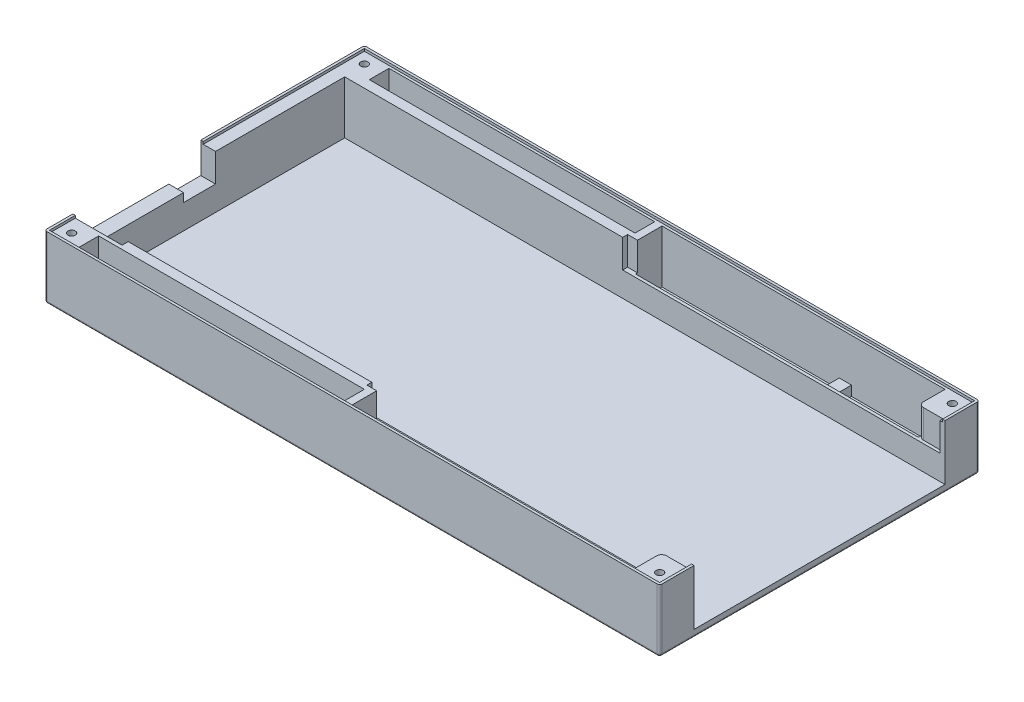
from build123d import *

# Parameters (mm, degrees)
SKETCH1_W             = 250
SKETCH1_H             = 130
BOSS_EXTRUDE1_DEPTH   = 3
SKETCH2_W             = 250
SKETCH2_H             = 1
BOSS_EXTRUDE2_DEPTH   = 25.5
SKETCH3_W             = 250
SKETCH3_H             = 1
BOSS_EXTRUDE3_DEPTH   = 22.5
SKETCH4_W             = 1
SKETCH4_H             = 128
BOSS_EXTRUDE4_DEPTH   = 22.5
SKETCH6_W             = 1
SKETCH6_H             = 14
BOSS_EXTRUDE5_DEPTH   = 22.5
SKETCH7_W             = 1
SKETCH7_H             = 14
BOSS_EXTRUDE6_DEPTH   = 22.5
SKETCH8_W             = 1
SKETCH8_H             = 13
BOSS_EXTRUDE7_DEPTH   = 21.5
SKETCH10_W            = 247
SKETCH10_H            = 1
BOSS_EXTRUDE8_DEPTH   = 21.5
SKETCH11_W            = 1
SKETCH11_H            = 127
BOSS_EXTRUDE9_DEPTH   = 21.5
SKETCH14_W            = 247
SKETCH14_H            = 1
BOSS_EXTRUDE10_DEPTH  = 21.5
SKETCH15_W            = 1
SKETCH15_H            = 12
BOSS_EXTRUDE11_DEPTH  = 21.5
FILLET1_R             = 1
SKETCH17_W            = 128
SKETCH17_H            = 1.2
BOSS_EXTRUDE12_DEPTH  = 10
SKETCH19_W            = 128
SKETCH19_H            = 1.2
BOSS_EXTRUDE13_DEPTH  = 10
SKETCH22_W            = 3
SKETCH22_H            = 10.8
BOSS_EXTRUDE14_DEPTH  = 21.5
SKETCH24_W            = 3
SKETCH24_H            = 10.8
BOSS_EXTRUDE15_DEPTH  = 21.5
SKETCH31_W            = 5
SKETCH31_H            = 10.8
BOSS_EXTRUDE16_DEPTH  = 4
SKETCH33_W            = 5
SKETCH33_H            = 10.8
BOSS_EXTRUDE18_DEPTH  = 4
SKETCH44_W            = 118
SKETCH44_H            = 4
BOSS_EXTRUDE28_DEPTH  = 21.5
SKETCH45_W            = 10
SKETCH45_H            = 12
BOSS_EXTRUDE29_DEPTH  = 21.5
SKETCH46_W            = 10
SKETCH46_H            = 8
BOSS_EXTRUDE30_DEPTH  = 21.5
SKETCH47_W            = 10
SKETCH47_H            = 10.8
BOSS_EXTRUDE31_DEPTH  = 21.5
SKETCH48_W            = 10
SKETCH48_H            = 10.8
BOSS_EXTRUDE32_DEPTH  = 21.5
SKETCH49_W            = 108
SKETCH49_H            = 4
BOSS_EXTRUDE33_DEPTH  = 21.5
SKETCH62_R            = 1.5
CASEMUNTHOLE001_DEPTH = 18
SKETCH63_R            = 1.5
CASEMUNTHOLE002_DEPTH = 18
SKETCH64_R            = 1.5
CASEMUNTHOLE003_DEPTH = 18
SKETCH65_R            = 1.5
CASEMUNTHOLE004_DEPTH = 18
SKETCH67_W            = 4
SKETCH67_H            = 102
BOSS_EXTRUDE35_DEPTH  = 21.5
SKETCH72_W            = 39
SKETCH72_H            = 9
CUT_EXTRUDE1_DEPTH    = 20
SKETCH73_W            = 13
SKETCH73_H            = 12.5
CUT_EXTRUDE2_DEPTH    = 20
SKETCH74_W            = 4
SKETCH74_H            = 2
CUT_EXTRUDE3_DEPTH    = 11.5
SKETCH75_W            = 4
SKETCH75_H            = 2
CUT_EXTRUDE4_DEPTH    = 11.5
FILLET2_R             = 2


with BuildPart() as part:
    # Sketch1 → Boss-Extrude1 (new body)
    with BuildSketch(Plane(origin=(0, 0, 0), x_dir=(1, 0, 0), z_dir=(0, 1, 0))):
        Rectangle(SKETCH1_W, SKETCH1_H)
    extrude(amount=BOSS_EXTRUDE1_DEPTH)

    # Sketch2 → Boss-Extrude2 (add)
    with BuildSketch(Plane(origin=(0, 0, 0), x_dir=(1, 0, 0), z_dir=(0, 1, 0))):
        with Locations((0, 64.5)):
            Rectangle(SKETCH2_W, SKETCH2_H)
    extrude(amount=BOSS_EXTRUDE2_DEPTH)

    # Sketch3 → Boss-Extrude3 (add)
    with BuildSketch(Plane(origin=(0, 3, 0), x_dir=(1, 0, 0), z_dir=(0, 1, 0))):
        with Locations((0, -64.5)):
            Rectangle(SKETCH3_W, SKETCH3_H)
    extrude(amount=BOSS_EXTRUDE3_DEPTH)

    # Sketch4 → Boss-Extrude4 (add)
    with BuildSketch(Plane(origin=(0, 3, 0), x_dir=(1, 0, 0), z_dir=(0, 1, 0))):
        with Locations((-124.5, 0)):
            Rectangle(SKETCH4_W, SKETCH4_H)
    extrude(amount=BOSS_EXTRUDE4_DEPTH)

    # Sketch6 → Boss-Extrude5 (add)
    with BuildSketch(Plane(origin=(0, 3, 0), x_dir=(1, 0, 0), z_dir=(0, 1, 0))):
        with Locations((124.5, -58)):
            Rectangle(SKETCH6_W, SKETCH6_H)
    extrude(amount=BOSS_EXTRUDE5_DEPTH)

    # Sketch7 → Boss-Extrude6 (add)
    with BuildSketch(Plane(origin=(0, 3, 0), x_dir=(1, 0, 0), z_dir=(0, 1, 0))):
        with Locations((124.5, 58)):
            Rectangle(SKETCH7_W, SKETCH7_H)
    extrude(amount=BOSS_EXTRUDE6_DEPTH)

    # Sketch8 → Boss-Extrude7 (add)
    with BuildSketch(Plane(origin=(0, 3, 0), x_dir=(1, 0, 0), z_dir=(0, 1, 0))):
        with Locations((123.5, 57.5)):
            Rectangle(SKETCH8_W, SKETCH8_H)
    extrude(amount=BOSS_EXTRUDE7_DEPTH)

    # Sketch10 → Boss-Extrude8 (add)
    with BuildSketch(Plane(origin=(0, 3, 0), x_dir=(1, 0, 0), z_dir=(0, 1, 0))):
        with Locations((-0.5, 63.5)):
            Rectangle(SKETCH10_W, SKETCH10_H)
    extrude(amount=BOSS_EXTRUDE8_DEPTH)

    # Sketch11 → Boss-Extrude9 (add)
    with BuildSketch(Plane(origin=(0, 3, 0), x_dir=(1, 0, 0), z_dir=(0, 1, 0))):
        with Locations((-123.5, -0.5)):
            Rectangle(SKETCH11_W, SKETCH11_H)
    extrude(amount=BOSS_EXTRUDE9_DEPTH)

    # Sketch14 → Boss-Extrude10 (add)
    with BuildSketch(Plane(origin=(0, 3, 0), x_dir=(1, 0, 0), z_dir=(0, 1, 0))):
        with Locations((0.5, -63.5)):
            Rectangle(SKETCH14_W, SKETCH14_H)
    extrude(amount=BOSS_EXTRUDE10_DEPTH)

    # Sketch15 → Boss-Extrude11 (add)
    with BuildSketch(Plane(origin=(0, 3, 0), x_dir=(1, 0, 0), z_dir=(0, 1, 0))):
        with Locations((123.5, -57)):
            Rectangle(SKETCH15_W, SKETCH15_H)
    extrude(amount=BOSS_EXTRUDE11_DEPTH)

    # Fillet1
    fillet1_edges = [part.edges().sort_by_distance(p)[0] for p in [
        (0, 0, 65),
        (-125, 0, 0),
        (0, 0, -65),
        (125, 0, 0),
        (125, 12.75, 65),
        (-125, 12.75, 65),
        (-125, 12.75, -65),
        (125, 12.75, -65),
    ]]
    fillet(fillet1_edges, radius=FILLET1_R)

    # Sketch17 → Boss-Extrude12 (add)
    with BuildSketch(Plane(origin=(0, 3, 0), x_dir=(1, 0, 0), z_dir=(0, 1, 0))):
        with Locations((59, 51.6)):
            Rectangle(SKETCH17_W, SKETCH17_H)
    extrude(amount=BOSS_EXTRUDE12_DEPTH)

    # Sketch19 → Boss-Extrude13 (add)
    with BuildSketch(Plane(origin=(0, 3, 0), x_dir=(1, 0, 0), z_dir=(0, 1, 0))):
        with Locations((59, -51.6)):
            Rectangle(SKETCH19_W, SKETCH19_H)
    extrude(amount=BOSS_EXTRUDE13_DEPTH)

    # Sketch22 → Boss-Extrude14 (add)
    with BuildSketch(Plane(origin=(0, 3, 0), x_dir=(1, 0, 0), z_dir=(0, 1, 0))):
        with Locations((-3.5, -57.6)):
            Rectangle(SKETCH22_W, SKETCH22_H)
    extrude(amount=BOSS_EXTRUDE14_DEPTH)

    # Sketch24 → Boss-Extrude15 (add)
    with BuildSketch(Plane(origin=(0, 3, 0), x_dir=(1, 0, 0), z_dir=(0, 1, 0))):
        with Locations((-3.5, 57.6)):
            Rectangle(SKETCH24_W, SKETCH24_H)
    extrude(amount=BOSS_EXTRUDE15_DEPTH)

    # Sketch31 → Boss-Extrude16 (add)
    with BuildSketch(Plane(origin=(0, 3, 0), x_dir=(1, 0, 0), z_dir=(0, 1, 0))):
        with Locations((72.5, -57.6)):
            Rectangle(SKETCH31_W, SKETCH31_H)
    extrude(amount=BOSS_EXTRUDE16_DEPTH)

    # Sketch33 → Boss-Extrude18 (add)
    with BuildSketch(Plane(origin=(0, 3, 0), x_dir=(1, 0, 0), z_dir=(0, 1, 0))):
        with Locations((72.5, 57.6)):
            Rectangle(SKETCH33_W, SKETCH33_H)
    extrude(amount=BOSS_EXTRUDE18_DEPTH)

    # Sketch44 → Boss-Extrude28 (add)
    with BuildSketch(Plane(origin=(0, 3, 0), x_dir=(1, 0, 0), z_dir=(0, 1, 0))):
        with Locations((-64, -53)):
            Rectangle(SKETCH44_W, SKETCH44_H)
    extrude(amount=BOSS_EXTRUDE28_DEPTH)

    # Sketch45 → Boss-Extrude29 (add)
    with BuildSketch(Plane(origin=(0, 3, 0), x_dir=(1, 0, 0), z_dir=(0, 1, 0))):
        with Locations((-118, 57)):
            Rectangle(SKETCH45_W, SKETCH45_H)
    extrude(amount=BOSS_EXTRUDE29_DEPTH)

    # Sketch46 → Boss-Extrude30 (add)
    with BuildSketch(Plane(origin=(0, 3, 0), x_dir=(1, 0, 0), z_dir=(0, 1, 0))):
        with Locations((-118, -59)):
            Rectangle(SKETCH46_W, SKETCH46_H)
    extrude(amount=BOSS_EXTRUDE30_DEPTH)

    # Sketch47 → Boss-Extrude31 (add)
    with BuildSketch(Plane(origin=(0, 3, 0), x_dir=(1, 0, 0), z_dir=(0, 1, 0))):
        with Locations((118, 57.6)):
            Rectangle(SKETCH47_W, SKETCH47_H)
    extrude(amount=BOSS_EXTRUDE31_DEPTH)

    # Sketch48 → Boss-Extrude32 (add)
    with BuildSketch(Plane(origin=(0, 3, 0), x_dir=(1, 0, 0), z_dir=(0, 1, 0))):
        with Locations((118, -57.6)):
            Rectangle(SKETCH48_W, SKETCH48_H)
    extrude(amount=BOSS_EXTRUDE32_DEPTH)

    # Sketch49 → Boss-Extrude33 (add)
    with BuildSketch(Plane(origin=(0, 3, 0), x_dir=(1, 0, 0), z_dir=(0, 1, 0))):
        with Locations((-59, 53)):
            Rectangle(SKETCH49_W, SKETCH49_H)
    extrude(amount=BOSS_EXTRUDE33_DEPTH)

    # Sketch62 → CaseMuntHole001 (cut)
    with BuildSketch(Plane(origin=(0, 24.5, 0), x_dir=(1, 0, 0), z_dir=(0, 1, 0))):
        with Locations((-119.5, 59.5)):
            Circle(SKETCH62_R)
    extrude(amount=-CASEMUNTHOLE001_DEPTH, mode=Mode.SUBTRACT)

    # Sketch63 → CaseMuntHole002 (cut)
    with BuildSketch(Plane(origin=(0, 24.5, 0), x_dir=(1, 0, 0), z_dir=(0, 1, 0))):
        with Locations((119.5, 59.5)):
            Circle(SKETCH63_R)
    extrude(amount=-CASEMUNTHOLE002_DEPTH, mode=Mode.SUBTRACT)

    # Sketch64 → CaseMuntHole003 (cut)
    with BuildSketch(Plane(origin=(0, 24.5, 0), x_dir=(1, 0, 0), z_dir=(0, 1, 0))):
        with Locations((119.5, -59.5)):
            Circle(SKETCH64_R)
    extrude(amount=-CASEMUNTHOLE003_DEPTH, mode=Mode.SUBTRACT)

    # Sketch65 → CaseMuntHole004 (cut)
    with BuildSketch(Plane(origin=(0, 24.5, 0), x_dir=(1, 0, 0), z_dir=(0, 1, 0))):
        with Locations((-119.5, -59.5)):
            Circle(SKETCH65_R)
    extrude(amount=-CASEMUNTHOLE004_DEPTH, mode=Mode.SUBTRACT)

    # Sketch67 → Boss-Extrude35 (add)
    with BuildSketch(Plane(origin=(0, 3, 0), x_dir=(1, 0, 0), z_dir=(0, 1, 0))):
        with Locations((-121, 0)):
            Rectangle(SKETCH67_W, SKETCH67_H)
    extrude(amount=BOSS_EXTRUDE35_DEPTH)

    # Sketch72 → Cut-Extrude1 (cut)
    with BuildSketch(Plane.ZY.offset(125)):
        with Locations((34, 21)):
            Rectangle(SKETCH72_W, SKETCH72_H)
    extrude(amount=-CUT_EXTRUDE1_DEPTH, mode=Mode.SUBTRACT)

    # Sketch73 → Cut-Extrude2 (cut)
    with BuildSketch(Plane.ZY.offset(125)):
        with Locations((8, 19.25)):
            Rectangle(SKETCH73_W, SKETCH73_H)
    extrude(amount=-CUT_EXTRUDE2_DEPTH, mode=Mode.SUBTRACT)

    # Sketch74 → Cut-Extrude3 (cut)
    with BuildSketch(Plane(origin=(0, 24.5, 0), x_dir=(1, 0, 0), z_dir=(0, 1, 0))):
        with Locations((-4, -52)):
            Rectangle(SKETCH74_W, SKETCH74_H)
    extrude(amount=-CUT_EXTRUDE3_DEPTH, mode=Mode.SUBTRACT)

    # Sketch75 → Cut-Extrude4 (cut)
    with BuildSketch(Plane(origin=(0, 24.5, 0), x_dir=(1, 0, 0), z_dir=(0, 1, 0))):
        with Locations((-4, 52)):
            Rectangle(SKETCH75_W, SKETCH75_H)
    extrude(amount=-CUT_EXTRUDE4_DEPTH, mode=Mode.SUBTRACT)

    # Fillet2
    fillet2_edges = [part.edges().sort_by_distance(p)[0] for p in [
        (113, 18.75, -52.2),
        (113, 18.75, 52.2),
    ]]
    fillet(fillet2_edges, radius=FILLET2_R)


solid = part.part
